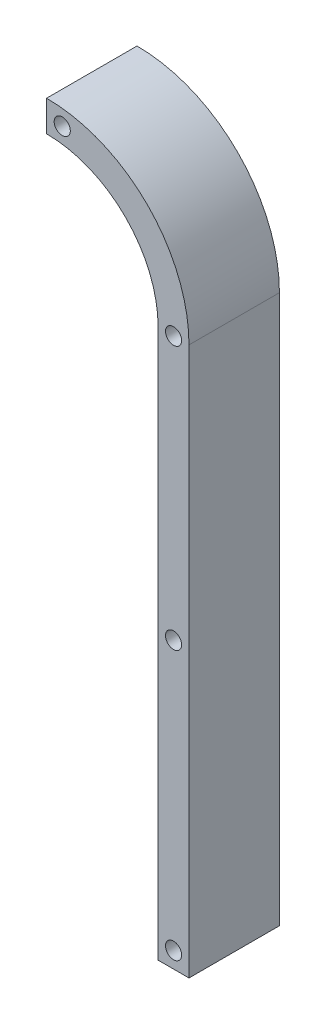
from build123d import *

# Parameters (mm, degrees)
SKETCH1_R           = 1.7
BOSS_EXTRUDE1_DEPTH = 19.05


with BuildPart() as part:
    # Sketch1 → Boss-Extrude1 (new body)
    with BuildSketch(Plane(origin=(0, 0, 0), x_dir=(-1, 0, 0), z_dir=(0, 0, -1))):
        with BuildLine():
            Line((149.085368151, 235.688334746), (149.085368151, 242.188334746))
            ThreePointArc((149.085368151, 242.188334746), (127.872164715, 233.401538181), (119.085368151, 212.188334746))
            Line((119.085368151, 212.188334746), (119.085368151, 96.699570281))
            Line((119.085368151, 96.699570281), (125.585368151, 96.699570281))
            Line((125.585368151, 96.699570281), (125.585368151, 212.188334746))
            ThreePointArc((125.585368151, 212.188334746), (132.468358793, 228.805344103), (149.085368151, 235.688334746))
        make_face()
        with Locations((145.785368151, 238.734002942)):
            Circle(SKETCH1_R, mode=Mode.SUBTRACT)
        with Locations((122.335368151, 212.188334746)):
            Circle(SKETCH1_R, mode=Mode.SUBTRACT)
        with Locations((122.335368151, 156.699570281)):
            Circle(SKETCH1_R, mode=Mode.SUBTRACT)
        with Locations((122.335368151, 100.099570281)):
            Circle(SKETCH1_R, mode=Mode.SUBTRACT)
    extrude(amount=-BOSS_EXTRUDE1_DEPTH)


solid = part.part
